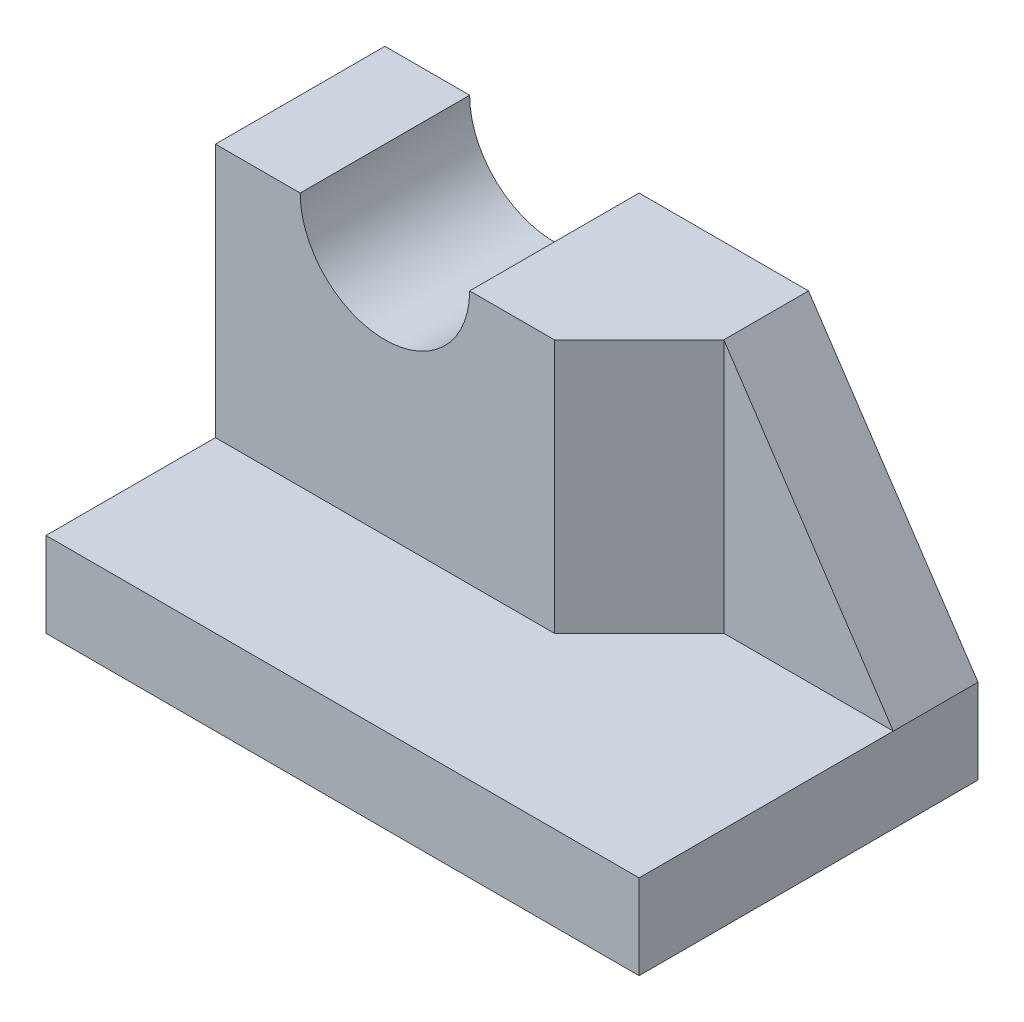
from build123d import *

# Parameters (mm, degrees)
SKETCH_1_W          = 35
SKETCH_1_H          = 20
EXTRUDE_1_DEPTH     = 5
EXTRUDE_2_DEPTH     = 20
CUT_EXTRUDE_1_DEPTH = 20
SCALE_1_SCALE       = 0.2


with BuildPart() as part:
    # 草圖1 → 填料-伸長1 (new body)
    with BuildSketch(Plane(origin=(0, 0, 0), x_dir=(1, 0, 0), z_dir=(0, 1, 0))):
        Rectangle(SKETCH_1_W, SKETCH_1_H)
    extrude(amount=EXTRUDE_1_DEPTH)

    # 草圖1<3> → 填料-伸長2 (add)
    with BuildSketch(Plane(origin=(0, 0, 0), x_dir=(1, 0, 0), z_dir=(0, 1, 0))):
        Polygon((2.5, 0), (7.5, 5), (17.5, 5), (17.5, 10), (-17.5, 10), (-17.5, 0), align=None)
    extrude(amount=EXTRUDE_2_DEPTH)

    # 草圖2 → 除料-伸長1 (cut)
    with BuildSketch(Plane.XY):
        with BuildLine():
            Line((-12.5, 20), (-2.5, 20))
            ThreePointArc((-2.5, 20), (-7.5, 15), (-12.5, 20))
        make_face()
        Polygon((17.5, 5), (7.5, 20), (17.5, 20), align=None)
    extrude(amount=-CUT_EXTRUDE_1_DEPTH, mode=Mode.SUBTRACT)


with BuildPart() as part_1:
    # 縮放比例1: scaled about (-1.822053886, 7.09893754, -2.737693345)
    add(part.part.scale(SCALE_1_SCALE).moved(Location((-1.457643109, 5.679150032, -2.190154676))))


solid = part_1.part
